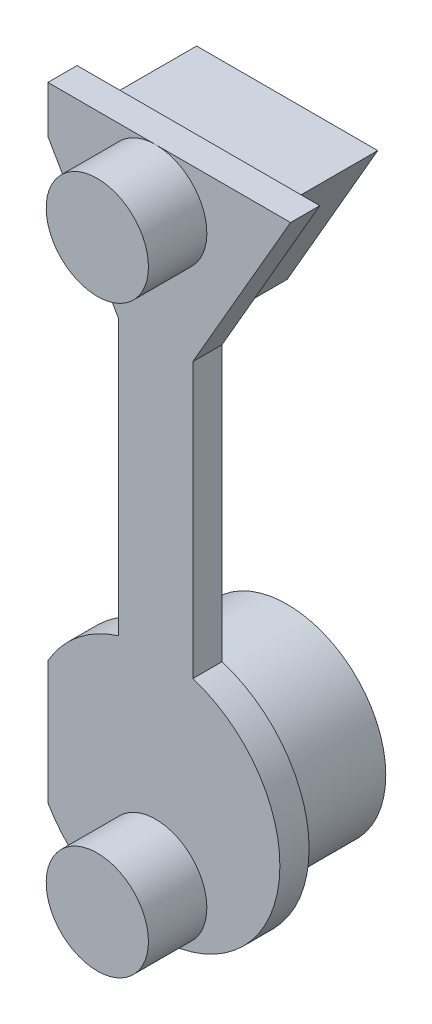
from build123d import *

# Parameters (mm, degrees)
SKETCH_5_R          = 3.4
EXTRUDE_2_DEPTH     = 0.8
EXTRUDE_2_2_DEPTH   = 0.8
SKETCH_6_W          = 2.031950572
SKETCH_6_H          = 7.518912136
EXTRUDE_3_DEPTH     = 0.8
SKETCH_7_R          = 2.7
EXTRUDE_4_DEPTH     = 2.8
SKETCH_8_R          = 1.4
EXTRUDE_5_DEPTH     = 1.6
SKETCH_9_W          = 4.279769968
SKETCH_9_H          = 23.306699104
CUT_EXTRUDE_1_DEPTH = 0.8


with BuildPart() as part:
    # Эскиз5 → Бобышка-Вытянуть2 (new body)
    with BuildSketch(Plane.XY):
        with Locations((0.12672506, -6)):
            Circle(SKETCH_5_R)
    extrude(amount=EXTRUDE_2_DEPTH)



with BuildPart() as body_2:
    # Эскиз5 → Extrude 2 2 (new body)
    with BuildSketch(Plane.XY):
        Polygon((-3.566095263, 9.4), (3.819545383, 9.4), (0.12672506, 3.003847577), align=None)
    extrude(amount=EXTRUDE_2_2_DEPTH)


with BuildPart() as part_1:
    add(part.part)

    add(body_2.part)  # Бобышка-Вытянуть3 merges body 2
    # Эскиз6 → Бобышка-Вытянуть3 (add)
    with BuildSketch(Plane(origin=(0, 0, 0), x_dir=(-1, 0, 0), z_dir=(0, 0, -1))):
        with Locations((-0.12672506, 1.004112324)):
            Rectangle(SKETCH_6_W, SKETCH_6_H)
    extrude(amount=-EXTRUDE_3_DEPTH)

    # Эскиз7 → Бобышка-Вытянуть4 (add)
    with BuildSketch(Plane(origin=(0, 0, 0), x_dir=(-1, 0, 0), z_dir=(0, 0, -1))):
        with Locations((-0.12672506, -6)):
            Circle(SKETCH_7_R)
        Polygon((-2.607109818, 8.7), (2.353659698, 8.7), (-0.12672506, 4.403847577), align=None)
    extrude(amount=EXTRUDE_4_DEPTH)

    # Эскиз8 → Бобышка-Вытянуть5 (add)
    with BuildSketch(Plane.XY.offset(0.8)):
        with Locations((0.12672506, 8)):
            Circle(SKETCH_8_R)
        with Locations((0.12672506, -8)):
            Circle(SKETCH_8_R)
    extrude(amount=EXTRUDE_5_DEPTH)

    # Эскиз9 → Вырез-Вытянуть1 (cut)
    with BuildSketch(Plane.XY.offset(0.8)):
        with Locations((-4.966610044, 0.180472228)):
            Rectangle(SKETCH_9_W, SKETCH_9_H)
    extrude(amount=-CUT_EXTRUDE_1_DEPTH, mode=Mode.SUBTRACT)


solid = part_1.part
